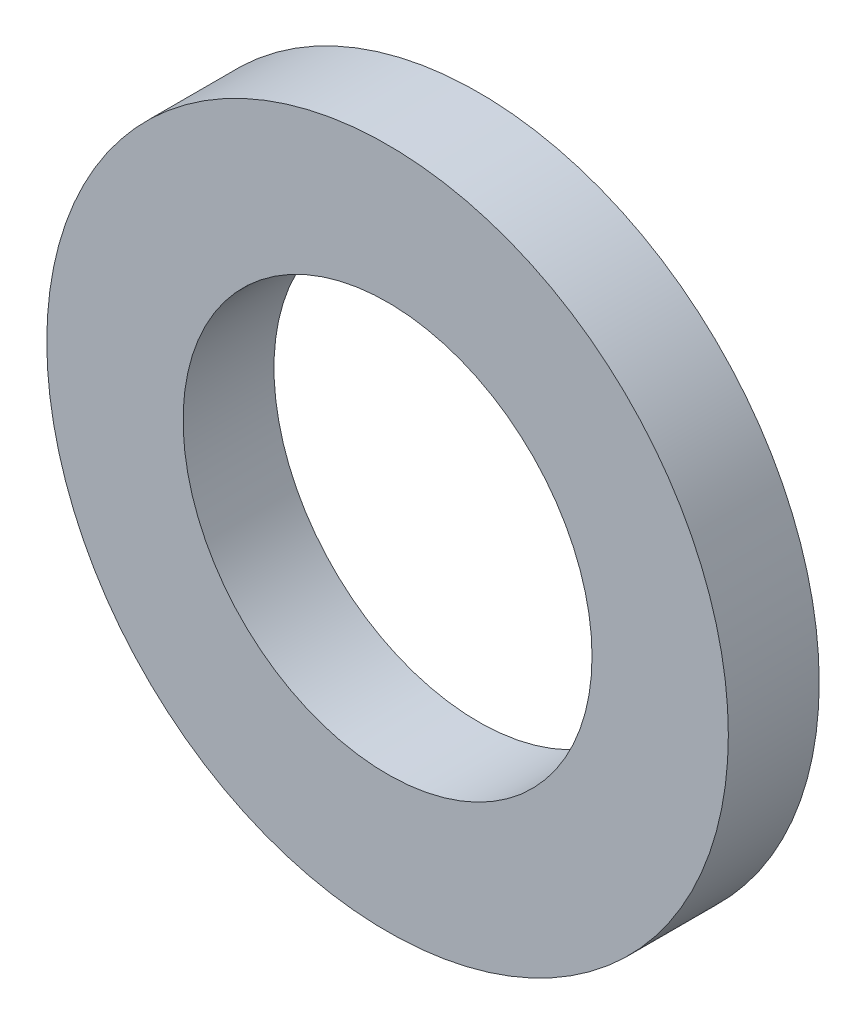
from build123d import *

# Parameters (mm, degrees)
SKETCH_1_R      = 7.5
SKETCH_1_R_2    = 4.5
EXTRUDE_1_DEPTH = 2


with BuildPart() as part:
    # 草圖1 → 填料-伸長1 (new body)
    with BuildSketch(Plane.XY):
        Circle(SKETCH_1_R)
        Circle(SKETCH_1_R_2, mode=Mode.SUBTRACT)
    extrude(amount=EXTRUDE_1_DEPTH)


solid = part.part
